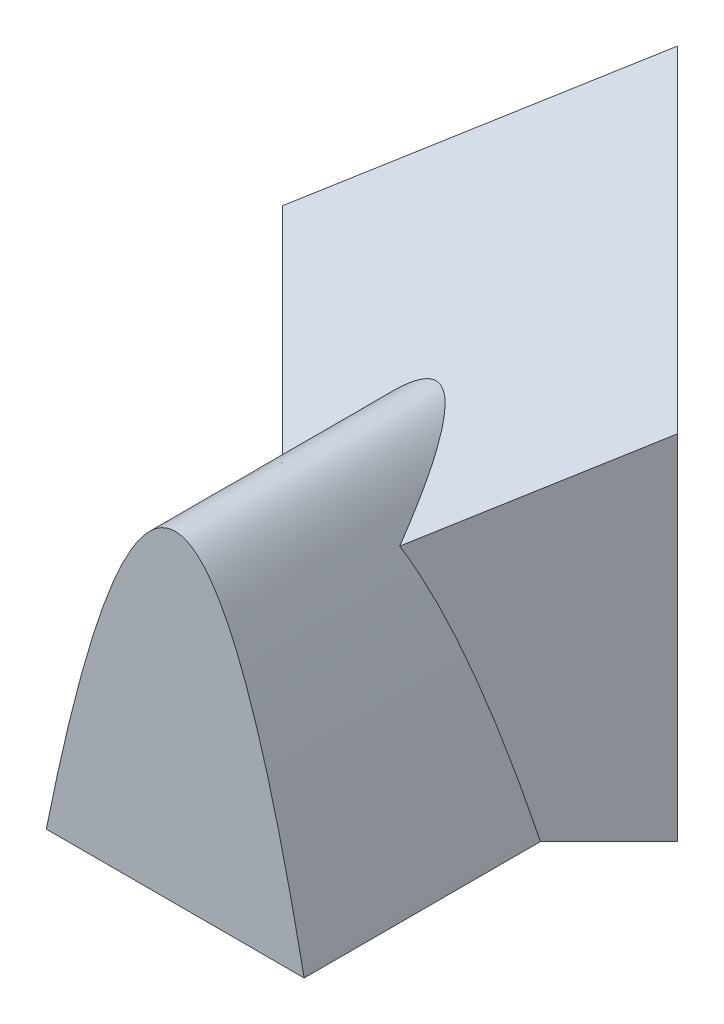
from build123d import *

# Parameters (mm, degrees)
EXTRUDE1_DEPTH      = 228.73
CUT_EXTRUDE1_DEPTH  = 95
EXTRUDE2_DEPTH      = 50
EXTRUDE2_DEPTH_BACK = 100


with BuildPart() as part:
    # Sketch1 → Extrude1 (new body)
    with BuildSketch(Plane(origin=(0, 0, 0), x_dir=(1, 0, 0), z_dir=(0, 1, 0))):
        Polygon((0, 0), (91.923881554, 91.923881554), (0, 183.847763109), (-91.923881554, 91.923881554), align=None)
    extrude(amount=EXTRUDE1_DEPTH)

    # Sketch2 → Cut-Extrude1 (cut, symmetric)
    with BuildSketch(Plane(origin=(0, 0, 0), x_dir=(0, 0, -1), z_dir=(1, 0, 0))):
        Polygon((0, 100), (183.847763109, 228.731589612), (0, 228.731589612), align=None)
    extrude(amount=CUT_EXTRUDE1_DEPTH, both=True, mode=Mode.SUBTRACT)

    # Sketch3 → Extrude2 (add, two sides)
    with BuildSketch(Plane.XY) as extrude2_sk:
        with BuildLine():
            Line((-60, 0), (60, 0))
            add(Edge.make_bspline(
                [(-60, 0), (0, 300), (60, 0)],
                knots=[0, 0, 0, 1, 1, 1], degree=2))
        make_face()
    extrude(amount=EXTRUDE2_DEPTH)
    extrude(extrude2_sk.sketch, amount=-EXTRUDE2_DEPTH_BACK)


solid = part.part
